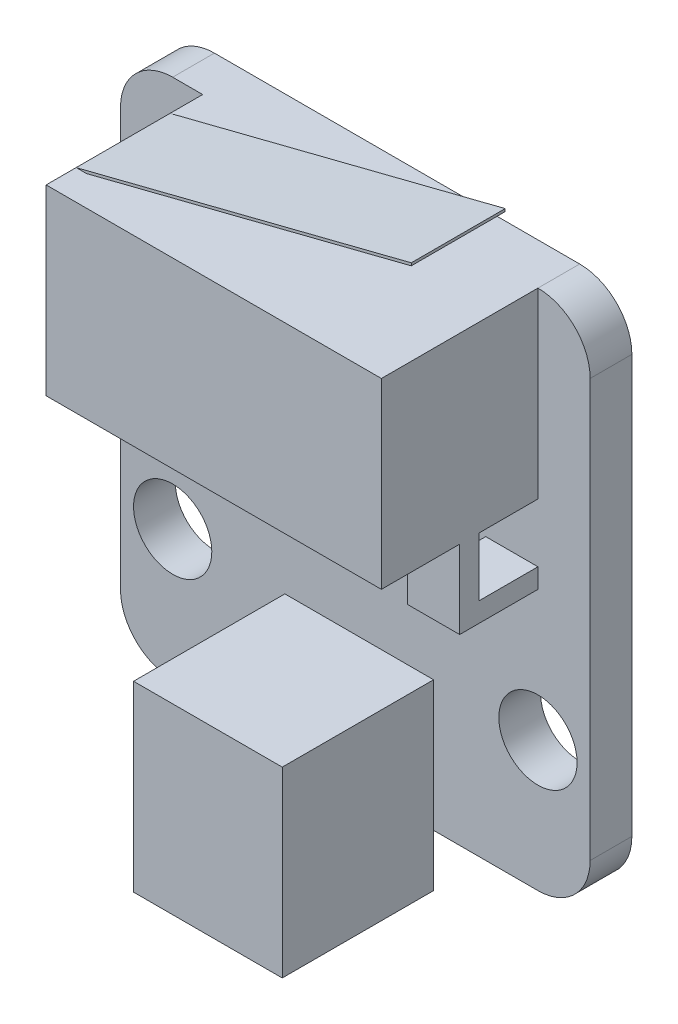
from build123d import *

# Parameters (mm, degrees)
SKETCH1_R           = 1.5
BOSS_EXTRUDE1_DEPTH = 1.6
SKETCH2_W           = 12.85
SKETCH2_H           = 10
BOSS_EXTRUDE2_DEPTH = 6
SKETCH3_W           = 12.85
SKETCH3_H           = 3
CUT_EXTRUDE1_DEPTH  = 3
CUT_EXTRUDE3_DEPTH  = 3
SKETCH5_W           = 2.25
SKETCH5_H           = 2.25
CUT_EXTRUDE4_DEPTH  = 17
BOSS_EXTRUDE4_DEPTH = 4.75
SKETCH11_W          = 12.85
SKETCH11_H          = 1.15
CUT_EXTRUDE8_DEPTH  = 4.75
SKETCH_1_W          = 5.7
SKETCH_1_H          = 7
EXTRUDE_1_DEPTH     = 5.8


with BuildPart() as part:
    # Sketch1 → Boss-Extrude1 (new body)
    with BuildSketch(Plane.XY):
        with BuildLine():
            Line((-7, 20), (7, 20))
            ThreePointArc((7, 20), (8.414213562, 19.414213562), (9, 18))
            Line((9, 18), (9, 2))
            ThreePointArc((9, 2), (8.414213562, 0.585786438), (7, 0))
            Line((7, 0), (-7, 0))
            ThreePointArc((-7, 0), (-8.414213562, 0.585786438), (-9, 2))
            Line((-9, 2), (-9, 18))
            ThreePointArc((-9, 18), (-8.414213562, 19.414213562), (-7, 20))
        make_face()
        with Locations((7, 5)):
            Circle(SKETCH1_R, mode=Mode.SUBTRACT)
        with Locations((-7, 5)):
            Circle(SKETCH1_R, mode=Mode.SUBTRACT)
    extrude(amount=BOSS_EXTRUDE1_DEPTH)

    # Sketch2 → Boss-Extrude2 (add)
    with BuildSketch(Plane.XY.offset(1.6)):
        with Locations((0.575, 15)):
            Rectangle(SKETCH2_W, SKETCH2_H)
    extrude(amount=BOSS_EXTRUDE2_DEPTH)

    # Sketch3 → Cut-Extrude1 (cut)
    with BuildSketch(Plane.XY.offset(7.6)):
        with Locations((0.575, 11.5)):
            Rectangle(SKETCH3_W, SKETCH3_H)
    extrude(amount=-CUT_EXTRUDE1_DEPTH, mode=Mode.SUBTRACT)

    # Sketch4 → Cut-Extrude3 (cut)
    with BuildSketch(Plane.XY.offset(4.6)):
        Polygon((5, 13), (1.575, 13), (1.575, 10), (5, 10), (5, 11.5), align=None)
        Polygon((-0.425, 13), (-3.85, 13), (-3.85, 11.5), (-3.85, 10), (-0.425, 10), align=None)
    extrude(amount=-CUT_EXTRUDE3_DEPTH, mode=Mode.SUBTRACT)

    # Sketch5 → Cut-Extrude4 (cut, through all)
    with BuildSketch(Plane(origin=(7, 0, 0), x_dir=(0, 0, -1), z_dir=(1, 0, 0))):
        with Locations((-2.725, 11.875)):
            Rectangle(SKETCH5_W, SKETCH5_H)
    extrude(amount=-CUT_EXTRUDE4_DEPTH, mode=Mode.SUBTRACT)

    # Sketch10 → Boss-Extrude4 (add)
    with BuildSketch(Plane.XY.offset(7.6)):
        Polygon((6.995, 23.262214419), (-5.85, 20), (-5.45, 20), (6.995, 23.16062736), align=None)
    extrude(amount=-BOSS_EXTRUDE4_DEPTH)

    # Sketch11 → Cut-Extrude8 (cut)
    with BuildSketch(Plane(origin=(0, 20, 0), x_dir=(1, 0, 0), z_dir=(0, 1, 0))):
        with Locations((0.575, -7.025)):
            Rectangle(SKETCH11_W, SKETCH11_H)
    extrude(amount=CUT_EXTRUDE8_DEPTH, mode=Mode.SUBTRACT)

    # 草图1 → 凸台-拉伸1 (add)
    with BuildSketch(Plane.XY.offset(1.6)):
        with Locations((0.15, 1.5)):
            Rectangle(SKETCH_1_W, SKETCH_1_H)
    extrude(amount=EXTRUDE_1_DEPTH)


solid = part.part
